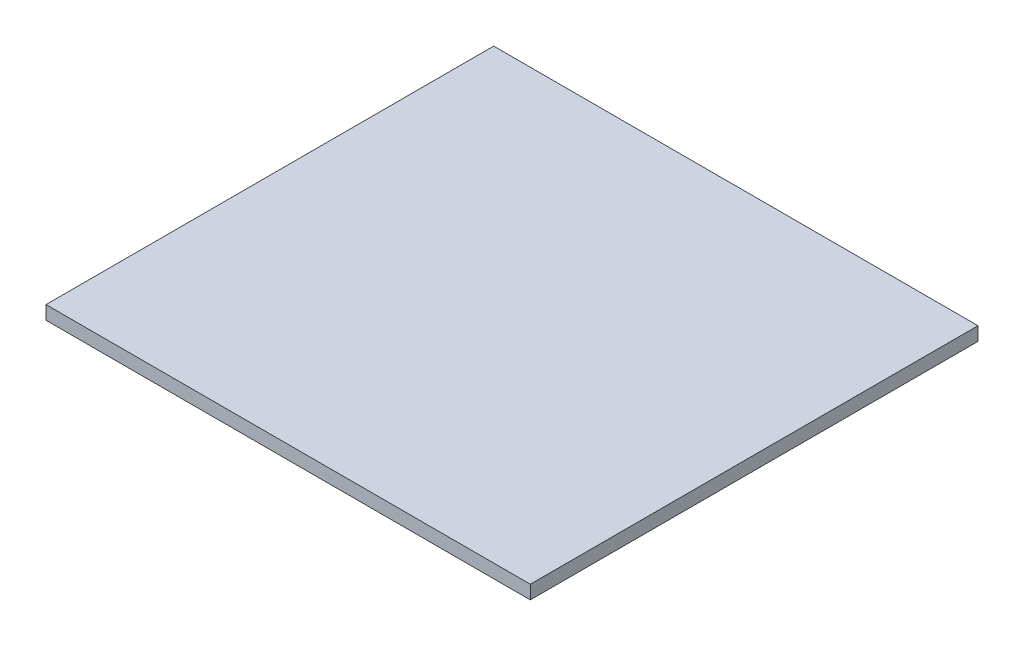
from build123d import *

# Parameters (mm, degrees)
SKETCH1_W           = 106.88
SKETCH1_H           = 98.8
BOSS_EXTRUDE1_DEPTH = 3


with BuildPart() as part:
    # Sketch1 → Boss-Extrude1 (new body)
    with BuildSketch(Plane(origin=(0, 0, 0), x_dir=(1, 0, 0), z_dir=(0, 1, 0))):
        with Locations((9.158457944, -28.701985981)):
            Rectangle(SKETCH1_W, SKETCH1_H)
    extrude(amount=BOSS_EXTRUDE1_DEPTH)


solid = part.part
